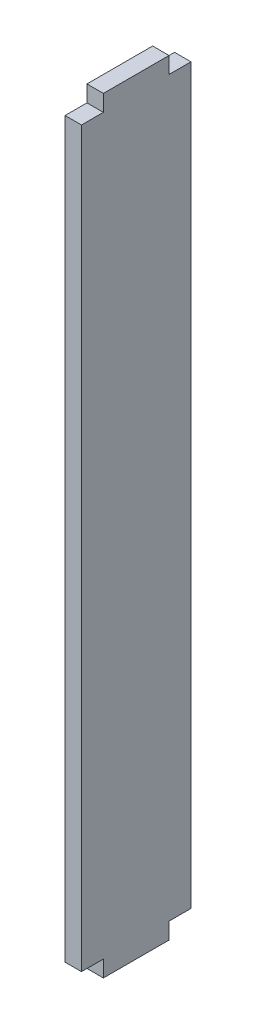
from build123d import *

# Parameters (mm, degrees)
SKETCH1_W           = 10
SKETCH1_H           = 70
BOSS_EXTRUDE1_DEPTH = 1.5
SKETCH2_W           = 2
SKETCH2_H           = 1.5
CUT_EXTRUDE1_DEPTH  = 10


with BuildPart() as part:
    # Sketch1 → Boss-Extrude1 (new body)
    with BuildSketch(Plane(origin=(0, 0, 0), x_dir=(0, 0, -1), z_dir=(1, 0, 0))):
        with Locations((-5, 4.155844156)):
            Rectangle(SKETCH1_W, SKETCH1_H)
    extrude(amount=BOSS_EXTRUDE1_DEPTH)

    # Sketch2 → Cut-Extrude1 (cut)
    with BuildSketch(Plane(origin=(1.5, 0, 0), x_dir=(0, 0, -1), z_dir=(1, 0, 0))):
        with Locations((-9, 38.405844156)):
            Rectangle(SKETCH2_W, SKETCH2_H)
        with Locations((-1, 38.405844156)):
            Rectangle(SKETCH2_W, SKETCH2_H)
        with Locations((-1, -30.094155844)):
            Rectangle(SKETCH2_W, SKETCH2_H)
        with Locations((-9, -30.094155844)):
            Rectangle(SKETCH2_W, SKETCH2_H)
    extrude(amount=-CUT_EXTRUDE1_DEPTH, mode=Mode.SUBTRACT)


solid = part.part
